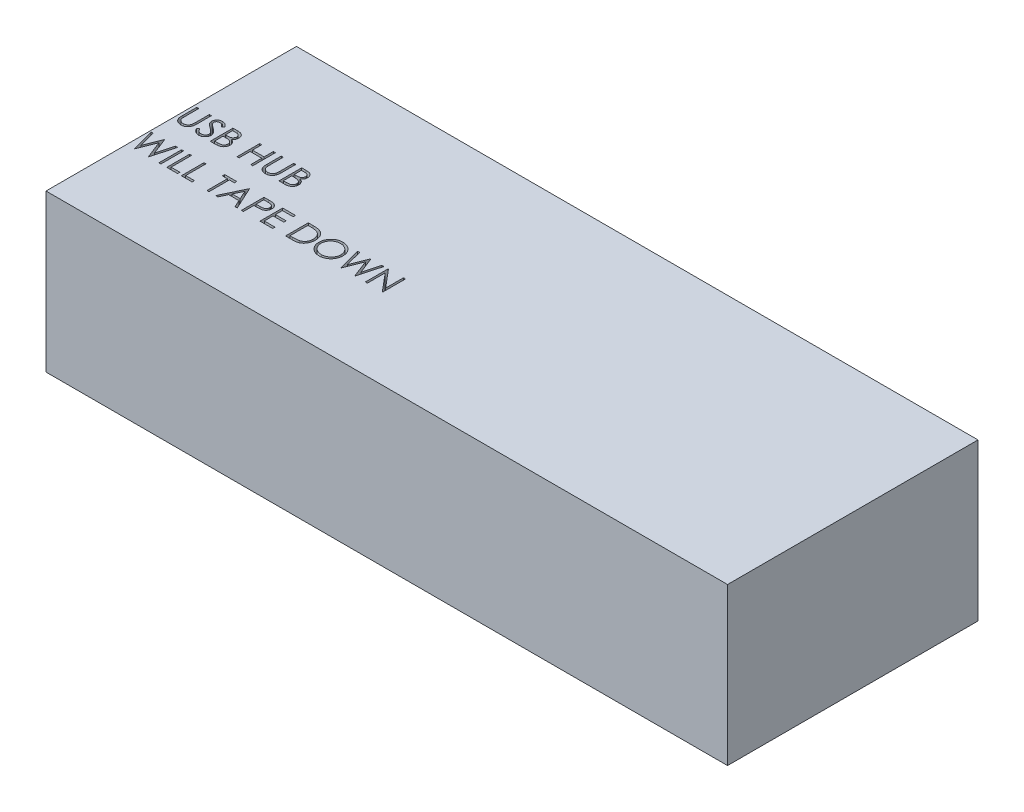
from build123d import *

# Parameters (mm, degrees)
SKETCH1_W           = 105.04
SKETCH1_H           = 38.6
BOSS_EXTRUDE1_DEPTH = 24.17
SKETCH2_W           = 0.314102564
SKETCH2_H           = 3.5
CUT_EXTRUDE1_DEPTH  = 25.17


with BuildPart() as part:
    # Sketch1 → Boss-Extrude1 (new body)
    with BuildSketch(Plane(origin=(0, 0, 0), x_dir=(1, 0, 0), z_dir=(0, 1, 0))):
        with Locations((52.52, 19.3)):
            Rectangle(SKETCH1_W, SKETCH1_H)
    extrude(amount=BOSS_EXTRUDE1_DEPTH)

    # Sketch2 → Cut-Extrude1 (cut, through all)
    with BuildSketch(Plane(origin=(0, 24.17, 0), x_dir=(1, 0, 0), z_dir=(0, 1, 0))):
        with BuildLine():
            Line((0.448717949, 22.8), (0.762820513, 22.8))
            Line((0.762820513, 22.8), (0.762820513, 20.702944712))
            add(Edge.make_bspline(
                [(0.762820513, 20.702944712), (0.762773769, 20.673263976), (0.762685064, 20.616939665), (0.763277578, 20.536771364), (0.764936946, 20.465498905), (0.765983106, 20.402847558), (0.768310439, 20.34910481), (0.770208486, 20.3039795), (0.772649043, 20.267685297), (0.775582161, 20.246504371), (0.776842949, 20.23739984)],
                knots=[0, 0, 0, 0, 8.9042e-05, 0.000168973, 0.000240502, 0.000302917, 0.000356945, 0.000401866, 0.000438432, 0.000465999, 0.000465999, 0.000465999, 0.000465999], degree=3))
            add(Edge.make_bspline(
                [(0.776842949, 20.23739984), (0.782020408, 20.204553076), (0.792083594, 20.140710347), (0.817729972, 20.049802065), (0.853547473, 19.967870607), (0.895990515, 19.892359316), (0.951923127, 19.825369956), (1.018926662, 19.763658303), (1.100104431, 19.709686499), (1.190365036, 19.660335687), (1.287650274, 19.620670604), (1.38706154, 19.59067724), (1.487104519, 19.57239834), (1.554080684, 19.570281801), (1.587339744, 19.569230769)],
                knots=[0, 0, 0, 0, 9.971e-05, 0.000193801, 0.000282365, 0.000367504, 0.000452699, 0.000543015, 0.000639862, 0.000744331, 0.000851226, 0.000954377, 0.001055468, 0.001155185, 0.001155185, 0.001155185, 0.001155185], degree=3))
            add(Edge.make_bspline(
                [(1.587339744, 19.569230769), (1.615893484, 19.57030462), (1.672836046, 19.572446118), (1.757442477, 19.585707549), (1.839842585, 19.609608115), (1.920443265, 19.640447873), (1.99599425, 19.681195464), (2.066537692, 19.728266303), (2.129501626, 19.78347718), (2.186959624, 19.844577524), (2.236994559, 19.913517324), (2.280365701, 19.988795462), (2.315891631, 20.071544809), (2.333435156, 20.129699231), (2.342447917, 20.159575321)],
                knots=[0, 0, 0, 0, 8.5678e-05, 0.00017086, 0.000256092, 0.000342674, 0.000429242, 0.000513055, 0.000596556, 0.000679898, 0.000764179, 0.00085149, 0.000940054, 0.001033621, 0.001033621, 0.001033621, 0.001033621], degree=3))
            add(Edge.make_bspline(
                [(2.342447917, 20.159575321), (2.345448042, 20.171923895), (2.35213353, 20.199441495), (2.358380575, 20.245962785), (2.364887101, 20.300852149), (2.369401671, 20.364503962), (2.373802891, 20.436704935), (2.376435964, 20.517831192), (2.377652997, 20.607588153), (2.378015677, 20.670225315), (2.378205128, 20.702944712)],
                knots=[0, 0, 0, 0, 3.81e-05, 8.4902e-05, 0.000140649, 0.000203941, 0.000276279, 0.000357657, 0.000447412, 0.000545571, 0.000545571, 0.000545571, 0.000545571], degree=3))
            Line((2.378205128, 20.702944712), (2.378205128, 22.8))
            Line((2.378205128, 22.8), (2.692307692, 22.8))
            Line((2.692307692, 22.8), (2.692307692, 20.686117788))
            add(Edge.make_bspline(
                [(2.692307692, 20.686117788), (2.692053572, 20.64801941), (2.691557641, 20.573668107), (2.687257064, 20.464716748), (2.680400064, 20.361363766), (2.670711976, 20.26359527), (2.657874973, 20.171761111), (2.643599753, 20.085056342), (2.625420219, 20.00410335), (2.604186818, 19.928270932), (2.57991327, 19.856085419), (2.548472122, 19.787576804), (2.513047622, 19.720662404), (2.471032969, 19.656354295), (2.423821586, 19.594367742), (2.370369906, 19.535078667), (2.312445745, 19.477539621), (2.249086185, 19.423226555), (2.18133566, 19.373417878), (2.109395702, 19.329620107), (2.033818933, 19.292596489), (1.954801806, 19.262120565), (1.872310604, 19.239205966), (1.786343244, 19.22213081), (1.69670405, 19.212428513), (1.635739394, 19.210986582), (1.604867788, 19.21025641)],
                knots=[0, 0, 0, 0, 0.000114291, 0.000223047, 0.000327049, 0.000424998, 0.000517708, 0.000605194, 0.000688542, 0.000766455, 0.0008414, 0.000916717, 0.000992315, 0.001068354, 0.001146882, 0.001225836, 0.001307639, 0.001391671, 0.001475952, 0.001559641, 0.001643989, 0.001728103, 0.001813335, 0.001900511, 0.00199079, 0.002083404, 0.002083404, 0.002083404, 0.002083404], degree=3))
            add(Edge.make_bspline(
                [(1.604867788, 19.21025641), (1.571198686, 19.211041176), (1.505140027, 19.212580882), (1.40780196, 19.221403632), (1.314487763, 19.238022027), (1.224211886, 19.25918197), (1.138203389, 19.288365708), (1.055309945, 19.322463832), (0.976951264, 19.364341093), (0.901856135, 19.410934486), (0.832031379, 19.463359124), (0.767933976, 19.520499298), (0.709458105, 19.581439675), (0.657589409, 19.646840041), (0.611468524, 19.716191748), (0.571738311, 19.789690988), (0.537625067, 19.867309304), (0.5200185, 19.921262504), (0.511117788, 19.94853766)],
                knots=[0, 0, 0, 0, 0.000101022, 0.000198206, 0.000292839, 0.000385177, 0.00047608, 0.000565014, 0.000653769, 0.000742283, 0.000829923, 0.000915339, 0.000999643, 0.001082971, 0.00116542, 0.001249186, 0.001333332, 0.001419362, 0.001419362, 0.001419362, 0.001419362], degree=3))
            add(Edge.make_bspline(
                [(0.511117788, 19.94853766), (0.50594063, 19.967170235), (0.494711259, 20.007584704), (0.482685961, 20.074471192), (0.47257688, 20.15148611), (0.463071321, 20.238634728), (0.457462363, 20.335984595), (0.452544925, 20.443493511), (0.448683306, 20.561291472), (0.448706078, 20.643345988), (0.448717949, 20.686117788)],
                knots=[0, 0, 0, 0, 5.799e-05, 0.000125782, 0.000203619, 0.000291034, 0.000388694, 0.000496078, 0.000613919, 0.000742226, 0.000742226, 0.000742226, 0.000742226], degree=3))
            Line((0.448717949, 20.686117788), (0.448717949, 22.8))
        make_face()
        with BuildLine():
            Line((3.230769231, 19.975180288), (3.526642628, 20.152564103))
            add(Edge.make_bspline(
                [(3.526642628, 20.152564103), (3.554160865, 20.106499718), (3.606884746, 20.018242134), (3.694836105, 19.898984093), (3.785969016, 19.797621937), (3.88095835, 19.714745329), (3.979224298, 19.649496442), (4.081408352, 19.603294211), (4.187166163, 19.574478235), (4.259139984, 19.570978149), (4.295072115, 19.569230769)],
                knots=[0, 0, 0, 0, 0.000160901, 0.00030828, 0.000443778, 0.00056903, 0.000685513, 0.000796284, 0.00090427, 0.001011928, 0.001011928, 0.001011928, 0.001011928], degree=3))
            add(Edge.make_bspline(
                [(4.295072115, 19.569230769), (4.325758976, 19.570085442), (4.386595749, 19.571779832), (4.476157992, 19.588060634), (4.563139794, 19.613072763), (4.645748432, 19.648893694), (4.722844046, 19.69223218), (4.790450742, 19.744578358), (4.848896855, 19.803184563), (4.89670597, 19.868567218), (4.933386005, 19.938884367), (4.961578073, 20.011060318), (4.977223147, 20.086228886), (4.9795799, 20.136839349), (4.980769231, 20.162379808)],
                knots=[0, 0, 0, 0, 9.1978e-05, 0.000182347, 0.000272202, 0.000362975, 0.000451852, 0.000536835, 0.000618639, 0.000699414, 0.000778765, 0.000855983, 0.0009312, 0.001007828, 0.001007828, 0.001007828, 0.001007828], degree=3))
            add(Edge.make_bspline(
                [(4.980769231, 20.162379808), (4.97929492, 20.191520657), (4.976297862, 20.250759747), (4.950966382, 20.3381594), (4.911117135, 20.42465197), (4.874354491, 20.478153235), (4.855268429, 20.505929487)],
                knots=[0, 0, 0, 0, 8.7281e-05, 0.000177429, 0.000270909, 0.000371844, 0.000371844, 0.000371844, 0.000371844], degree=3))
            add(Edge.make_bspline(
                [(4.855268429, 20.505929487), (4.839597815, 20.525976311), (4.806699321, 20.568062109), (4.750141808, 20.630707345), (4.683775694, 20.695325764), (4.609872139, 20.764384821), (4.52573905, 20.834672617), (4.434011536, 20.909540895), (4.332347677, 20.986142472), (4.26104818, 21.037515038), (4.224258814, 21.064022436)],
                knots=[0, 0, 0, 0, 7.6319e-05, 0.000160223, 0.000252933, 0.000354147, 0.000463581, 0.000581729, 0.000709336, 0.000845369, 0.000845369, 0.000845369, 0.000845369], degree=3))
            add(Edge.make_bspline(
                [(4.224258814, 21.064022436), (4.187434818, 21.090251024), (4.117030141, 21.140398086), (4.018571559, 21.21482237), (3.930527096, 21.282866239), (3.853288079, 21.345170251), (3.786888483, 21.401742856), (3.730805072, 21.452040795), (3.686466515, 21.497424356), (3.661810934, 21.526865698), (3.650741186, 21.540084135)],
                knots=[0, 0, 0, 0, 0.000135623, 0.000259301, 0.000370234, 0.000469439, 0.00055697, 0.000631911, 0.000695377, 0.00074709, 0.00074709, 0.00074709, 0.00074709], degree=3))
            add(Edge.make_bspline(
                [(3.650741186, 21.540084135), (3.635268641, 21.560685171), (3.604839804, 21.601199875), (3.564673798, 21.664524733), (3.530534636, 21.729347998), (3.503772304, 21.795843863), (3.481236085, 21.863078792), (3.466078154, 21.931930038), (3.456586757, 22.002088656), (3.455614771, 22.049302157), (3.455128205, 22.072936699)],
                knots=[0, 0, 0, 0, 7.727e-05, 0.000151962, 0.000224716, 0.000296717, 0.00036678, 0.0004372, 0.000507902, 0.000578771, 0.000578771, 0.000578771, 0.000578771], degree=3))
            add(Edge.make_bspline(
                [(3.455128205, 22.072936699), (3.456433414, 22.109966473), (3.459015934, 22.183234537), (3.480856451, 22.290265367), (3.515329345, 22.392451785), (3.563624233, 22.488782118), (3.625881586, 22.576748099), (3.69792756, 22.657361586), (3.783739046, 22.725130168), (3.87789167, 22.784342227), (3.980948042, 22.830688152), (4.088938945, 22.865649132), (4.202036017, 22.88545839), (4.278639152, 22.888301155), (4.317508013, 22.88974359)],
                knots=[0, 0, 0, 0, 0.000110999, 0.000219625, 0.000326272, 0.00043382, 0.000541574, 0.000648775, 0.000756959, 0.000868438, 0.000981703, 0.00109501, 0.001208203, 0.0013248, 0.0013248, 0.0013248, 0.0013248], degree=3))
            add(Edge.make_bspline(
                [(4.317508013, 22.88974359), (4.358752113, 22.888321038), (4.440773465, 22.885492037), (4.56142268, 22.860894506), (4.677583397, 22.820193834), (4.771026662, 22.774005176), (4.844159423, 22.72787376), (4.899932156, 22.685853936), (4.956449607, 22.637478827), (5.014167661, 22.582619581), (5.072108321, 22.52077283), (5.131131773, 22.452362141), (5.191376042, 22.377805585), (5.230131902, 22.324581085), (5.25, 22.297295673)],
                knots=[0, 0, 0, 0, 0.000123638, 0.000245877, 0.000367608, 0.000492088, 0.000557638, 0.000626769, 0.000701372, 0.00078072, 0.000865532, 0.000955497, 0.001051745, 0.001152989, 0.001152989, 0.001152989, 0.001152989], degree=3))
            Line((5.25, 22.297295673), (4.966045673, 22.082051282))
            add(Edge.make_bspline(
                [(4.966045673, 22.082051282), (4.948899741, 22.104139972), (4.915880684, 22.146677626), (4.865751197, 22.206248941), (4.818502549, 22.260665421), (4.771952149, 22.307930549), (4.728558518, 22.350632682), (4.686441475, 22.387192439), (4.646207124, 22.417968034), (4.595490213, 22.450811594), (4.531772495, 22.483368098), (4.451787959, 22.510917176), (4.368201684, 22.527472238), (4.311272052, 22.529661126), (4.282451923, 22.530769231)],
                knots=[0, 0, 0, 0, 8.3877e-05, 0.000161528, 0.000233552, 0.000299993, 0.000360485, 0.000416152, 0.000467195, 0.000512312, 0.000597287, 0.000681099, 0.000765389, 0.000851809, 0.000851809, 0.000851809, 0.000851809], degree=3))
            add(Edge.make_bspline(
                [(4.282451923, 22.530769231), (4.246295401, 22.529557531), (4.176570953, 22.527220882), (4.077580717, 22.501700896), (3.988486792, 22.461519036), (3.911934227, 22.405204058), (3.84819725, 22.338483065), (3.802091791, 22.26170421), (3.774341627, 22.176921808), (3.770955347, 22.117780151), (3.769230769, 22.087660256)],
                knots=[0, 0, 0, 0, 0.000108248, 0.000208746, 0.00030443, 0.000399793, 0.000492054, 0.00057947, 0.000666386, 0.000756591, 0.000756591, 0.000756591, 0.000756591], degree=3))
            add(Edge.make_bspline(
                [(3.769230769, 22.087660256), (3.769623896, 22.068908778), (3.770410792, 22.031375158), (3.78138559, 21.975923736), (3.795484919, 21.920612397), (3.81782755, 21.865689814), (3.848672854, 21.810195455), (3.88917803, 21.753173718), (3.940191342, 21.694122009), (3.979268354, 21.655714635), (3.99989984, 21.635436699)],
                knots=[0, 0, 0, 0, 5.616e-05, 0.000112411, 0.000169046, 0.000227244, 0.000289691, 0.000359134, 0.000436702, 0.000523463, 0.000523463, 0.000523463, 0.000523463], degree=3))
            add(Edge.make_bspline(
                [(3.99989984, 21.635436699), (4.007561212, 21.628599673), (4.025762879, 21.612356465), (4.059038805, 21.585764184), (4.102981603, 21.552961412), (4.156443804, 21.512374095), (4.220411166, 21.465292633), (4.294890722, 21.412319021), (4.379052255, 21.351733562), (4.438774171, 21.309376021), (4.470352564, 21.286979167)],
                knots=[0, 0, 0, 0, 3.0802e-05, 7.3177e-05, 0.000127725, 0.000195314, 0.000274544, 0.000365991, 0.000469501, 0.000585644, 0.000585644, 0.000585644, 0.000585644], degree=3))
            add(Edge.make_bspline(
                [(4.470352564, 21.286979167), (4.508338477, 21.259337807), (4.581892934, 21.205814145), (4.686550514, 21.125398465), (4.781444322, 21.046750697), (4.866907525, 20.97037309), (4.943784434, 20.896844997), (5.011222154, 20.825281816), (5.069907835, 20.756196244), (5.133087053, 20.667623668), (5.197644873, 20.558842584), (5.25308638, 20.425564345), (5.288044728, 20.291768025), (5.292616243, 20.201841188), (5.294871795, 20.157471955)],
                knots=[0, 0, 0, 0, 0.000140932, 0.000272896, 0.000395881, 0.000510584, 0.000616697, 0.000714904, 0.000805482, 0.000888372, 0.001041088, 0.001183793, 0.001320341, 0.001453327, 0.001453327, 0.001453327, 0.001453327], degree=3))
            add(Edge.make_bspline(
                [(5.294871795, 20.157471955), (5.294214657, 20.12609359), (5.292913142, 20.063946206), (5.277952228, 19.97269113), (5.256032563, 19.88406026), (5.222995329, 19.799149147), (5.182672171, 19.716404385), (5.131505923, 19.637996484), (5.072198238, 19.562190086), (5.004164473, 19.491006594), (4.929718571, 19.425660398), (4.851034876, 19.367531337), (4.767984603, 19.319063014), (4.681018286, 19.279512172), (4.59011595, 19.248578654), (4.495308166, 19.226165785), (4.396438655, 19.212410074), (4.329238173, 19.210982313), (4.295072115, 19.21025641)],
                knots=[0, 0, 0, 0, 9.4044e-05, 0.000186263, 0.000276729, 0.000367488, 0.000459046, 0.000552398, 0.000647774, 0.000747454, 0.000847311, 0.000944634, 0.001040472, 0.001135227, 0.001230788, 0.001328063, 0.00142712, 0.00152957, 0.00152957, 0.00152957, 0.00152957], degree=3))
            add(Edge.make_bspline(
                [(4.295072115, 19.21025641), (4.268636772, 19.210767592), (4.216099012, 19.211783517), (4.13838953, 19.220764798), (4.062249941, 19.233471901), (3.988635659, 19.253645971), (3.916598248, 19.278122948), (3.846451013, 19.308261281), (3.778159959, 19.344378482), (3.711342376, 19.385673507), (3.646168202, 19.433731252), (3.583248734, 19.489704748), (3.520519548, 19.552050253), (3.459832152, 19.622460816), (3.399959008, 19.699798899), (3.342080598, 19.784788083), (3.28499888, 19.876965436), (3.249183413, 19.941830522), (3.230769231, 19.975180288)],
                knots=[0, 0, 0, 0, 7.9276e-05, 0.000157554, 0.000234438, 0.000310629, 0.000386236, 0.000462555, 0.000539392, 0.000617798, 0.000698008, 0.000781971, 0.000870217, 0.00096315, 0.001060616, 0.001163492, 0.001271478, 0.00138575, 0.00138575, 0.00138575, 0.00138575], degree=3))
        make_face()
        with BuildLine():
            Line((6.012820513, 22.8), (6.695713141, 22.8))
            add(Edge.make_bspline(
                [(6.695713141, 22.8), (6.729141619, 22.79982425), (6.79393433, 22.799483602), (6.888153771, 22.79420047), (6.976402582, 22.786996801), (7.058706354, 22.775566708), (7.135027057, 22.761774931), (7.205594694, 22.745073115), (7.270184866, 22.725046501), (7.347297603, 22.69320022), (7.435218264, 22.645877051), (7.530416656, 22.575948486), (7.611820896, 22.490416023), (7.682007213, 22.393933368), (7.737808332, 22.287797596), (7.77817763, 22.174538407), (7.803735505, 22.055616665), (7.806363939, 21.973973487), (7.807692308, 21.93271234)],
                knots=[0, 0, 0, 0, 0.00010027, 0.000194349, 0.000283026, 0.000365821, 0.000443519, 0.000515622, 0.000583254, 0.00064614, 0.000765662, 0.000881909, 0.000998927, 0.001118415, 0.001238844, 0.00135727, 0.001478274, 0.001601912, 0.001601912, 0.001601912, 0.001601912], degree=3))
            add(Edge.make_bspline(
                [(7.807692308, 21.93271234), (7.806599089, 21.894059784), (7.804450812, 21.818103867), (7.783908053, 21.707009758), (7.751747384, 21.601258539), (7.707042135, 21.501236154), (7.648940139, 21.40920254), (7.58008182, 21.324415274), (7.497005018, 21.250464217), (7.434761778, 21.209121315), (7.403145032, 21.188120994)],
                knots=[0, 0, 0, 0, 0.000115857, 0.00022767, 0.000337672, 0.000446877, 0.000555233, 0.000663318, 0.000773539, 0.000887324, 0.000887324, 0.000887324, 0.000887324], degree=3))
            add(Edge.make_bspline(
                [(7.403145032, 21.188120994), (7.44290546, 21.172855995), (7.518977007, 21.14365027), (7.623663019, 21.092014806), (7.713857864, 21.035852696), (7.79025501, 20.974520846), (7.855592665, 20.908412035), (7.912645607, 20.836556921), (7.961326981, 20.758018163), (8.003039905, 20.673614627), (8.035588661, 20.584208159), (8.059964565, 20.490637383), (8.073932014, 20.393237828), (8.075919655, 20.326952448), (8.076923077, 20.293489583)],
                knots=[0, 0, 0, 0, 0.000127722, 0.000244363, 0.000349599, 0.000445847, 0.000537565, 0.000627901, 0.000720503, 0.000814257, 0.000909859, 0.001005428, 0.001103887, 0.001204268, 0.001204268, 0.001204268, 0.001204268], degree=3))
            add(Edge.make_bspline(
                [(8.076923077, 20.293489583), (8.075946231, 20.259322711), (8.074024259, 20.192098433), (8.059844287, 20.093343299), (8.03583518, 19.998968352), (8.002764034, 19.908363169), (7.959601719, 19.821703035), (7.907073755, 19.738889771), (7.844442191, 19.66075544), (7.774379322, 19.586431817), (7.695117177, 19.51960403), (7.609601422, 19.460088323), (7.516755102, 19.411142261), (7.418103108, 19.370026239), (7.312538792, 19.338619041), (7.200536185, 19.316646467), (7.082191883, 19.30184143), (7.000982132, 19.300624225), (6.959334936, 19.3)],
                knots=[0, 0, 0, 0, 0.000102481, 0.000201635, 0.000298562, 0.000394165, 0.000490425, 0.000588455, 0.000687769, 0.000790423, 0.000894381, 0.000998232, 0.001102369, 0.001208616, 0.001318415, 0.001432129, 0.001550749, 0.00167562, 0.00167562, 0.00167562, 0.00167562], degree=3))
            Line((6.959334936, 19.3), (6.012820513, 19.3))
            Line((6.012820513, 19.3), (6.012820513, 22.8))
        make_face()
        with BuildLine():
            Line((6.326923077, 22.441025641), (6.326923077, 21.319230769))
            Line((6.326923077, 21.319230769), (6.537960737, 21.319230769))
            add(Edge.make_bspline(
                [(6.537960737, 21.319230769), (6.568809533, 21.319630692), (6.628415692, 21.320403425), (6.714735588, 21.322616942), (6.794860607, 21.328814985), (6.86865244, 21.335011248), (6.935994884, 21.345085835), (6.996738745, 21.357077958), (7.051837342, 21.369760863), (7.115376888, 21.39133035), (7.187449836, 21.423208025), (7.26428294, 21.472679861), (7.33201741, 21.531604215), (7.389214597, 21.599595176), (7.436026068, 21.674461362), (7.468539783, 21.755008243), (7.490587067, 21.839228375), (7.492578599, 21.897046627), (7.493589744, 21.926402244)],
                knots=[0, 0, 0, 0, 9.2559e-05, 0.000178842, 0.000258967, 0.000333616, 0.000400942, 0.000463093, 0.000519379, 0.000570374, 0.000664201, 0.000755025, 0.000843472, 0.000932526, 0.001020669, 0.001107124, 0.001192318, 0.001280185, 0.001280185, 0.001280185, 0.001280185], degree=3))
            add(Edge.make_bspline(
                [(7.493589744, 21.926402244), (7.493063563, 21.945828015), (7.492031404, 21.983933787), (7.483578101, 22.039483141), (7.469210526, 22.091726894), (7.450756233, 22.141381004), (7.424967545, 22.186892854), (7.394604081, 22.22983605), (7.357918391, 22.268748169), (7.316161078, 22.305117667), (7.268152455, 22.337362195), (7.213921164, 22.365602958), (7.152733487, 22.388343735), (7.085620632, 22.408259887), (7.011549544, 22.422248181), (6.931374991, 22.433901569), (6.844440272, 22.439834311), (6.784295169, 22.440619673), (6.753205128, 22.441025641)],
                knots=[0, 0, 0, 0, 5.8261e-05, 0.000114285, 0.000168029, 0.000220632, 0.000272728, 0.000324483, 0.000378062, 0.000432741, 0.000490301, 0.000551137, 0.000615721, 0.000685833, 0.000760908, 0.00084162, 0.000928788, 0.00102206, 0.00102206, 0.00102206, 0.00102206], degree=3))
            Line((6.753205128, 22.441025641), (6.326923077, 22.441025641))
        make_face(mode=Mode.SUBTRACT)
        with BuildLine():
            Line((6.326923077, 20.96025641), (6.326923077, 19.658974359))
            Line((6.326923077, 19.658974359), (6.774238782, 19.658974359))
            add(Edge.make_bspline(
                [(6.774238782, 19.658974359), (6.806257708, 19.659358106), (6.867969967, 19.660097729), (6.957071197, 19.662512283), (7.0396543, 19.668004559), (7.115342436, 19.676650409), (7.184952889, 19.686028858), (7.247650592, 19.698640139), (7.303943785, 19.713089099), (7.369218093, 19.735423272), (7.442721601, 19.770119743), (7.521932458, 19.822433969), (7.592358676, 19.884757277), (7.652163935, 19.956888191), (7.701176924, 20.035319518), (7.736832379, 20.118464868), (7.758823235, 20.204950395), (7.761485405, 20.263917108), (7.762820513, 20.293489583)],
                knots=[0, 0, 0, 0, 9.6064e-05, 0.000185151, 0.000267373, 0.000344257, 0.000413665, 0.000478015, 0.000536005, 0.000587888, 0.000684801, 0.000778918, 0.000871787, 0.000965866, 0.001059062, 0.00114827, 0.001236355, 0.001324974, 0.001324974, 0.001324974, 0.001324974], degree=3))
            add(Edge.make_bspline(
                [(7.762820513, 20.293489583), (7.762544408, 20.311982924), (7.761996653, 20.348671306), (7.753736038, 20.402587125), (7.741722169, 20.454812998), (7.726190735, 20.505490739), (7.703571268, 20.553704115), (7.677164723, 20.600406675), (7.646203321, 20.645660154), (7.597959155, 20.702872407), (7.527787171, 20.76878942), (7.428080395, 20.833326923), (7.314708097, 20.88537473), (7.232480604, 20.907474206), (7.190004006, 20.918890224)],
                knots=[0, 0, 0, 0, 5.5429e-05, 0.000109963, 0.000163198, 0.000216191, 0.000268588, 0.000322593, 0.000377046, 0.000432793, 0.000546889, 0.000664343, 0.000787646, 0.000919405, 0.000919405, 0.000919405, 0.000919405], degree=3))
            add(Edge.make_bspline(
                [(7.190004006, 20.918890224), (7.172974911, 20.922345308), (7.136052318, 20.929836643), (7.075844738, 20.937744346), (7.007108869, 20.944789406), (6.929685992, 20.950000564), (6.843478151, 20.955387107), (6.748301232, 20.957481929), (6.644543917, 20.959981189), (6.572551545, 20.960162323), (6.53515625, 20.96025641)],
                knots=[0, 0, 0, 0, 5.2115e-05, 0.000112995, 0.000182062, 0.000259389, 0.000345767, 0.00044116, 0.000544948, 0.000657129, 0.000657129, 0.000657129, 0.000657129], degree=3))
            Line((6.53515625, 20.96025641), (6.326923077, 20.96025641))
        make_face(mode=Mode.SUBTRACT)
        Polygon((10.141025641, 22.8), (10.455128205, 22.8), (10.455128205, 21.364102564), (12.25, 21.364102564), (12.25, 22.8), (12.564102564, 22.8), (12.564102564, 19.3), (12.25, 19.3), (12.25, 21.005128205), (10.455128205, 21.005128205), (10.455128205, 19.3), (10.141025641, 19.3), align=None)
        with BuildLine():
            Line((13.461538462, 22.8), (13.775641026, 22.8))
            Line((13.775641026, 22.8), (13.775641026, 20.702944712))
            add(Edge.make_bspline(
                [(13.775641026, 20.702944712), (13.775594282, 20.673263976), (13.775505577, 20.616939665), (13.776098091, 20.536771364), (13.777757459, 20.465498905), (13.778803619, 20.402847558), (13.781130952, 20.34910481), (13.783028999, 20.3039795), (13.785469556, 20.267685297), (13.788402673, 20.246504371), (13.789663462, 20.23739984)],
                knots=[0, 0, 0, 0, 8.9042e-05, 0.000168973, 0.000240502, 0.000302917, 0.000356945, 0.000401866, 0.000438432, 0.000465999, 0.000465999, 0.000465999, 0.000465999], degree=3))
            add(Edge.make_bspline(
                [(13.789663462, 20.23739984), (13.79484092, 20.204553076), (13.804904107, 20.140710347), (13.830550484, 20.049802065), (13.866367985, 19.967870607), (13.908811028, 19.892359316), (13.96474364, 19.825369956), (14.031747175, 19.763658303), (14.112924943, 19.709686499), (14.203185549, 19.660335687), (14.300470787, 19.620670604), (14.399882053, 19.59067724), (14.499925032, 19.57239834), (14.566901197, 19.570281801), (14.600160256, 19.569230769)],
                knots=[0, 0, 0, 0, 9.971e-05, 0.000193801, 0.000282365, 0.000367504, 0.000452699, 0.000543015, 0.000639862, 0.000744331, 0.000851226, 0.000954377, 0.001055468, 0.001155185, 0.001155185, 0.001155185, 0.001155185], degree=3))
            add(Edge.make_bspline(
                [(14.600160256, 19.569230769), (14.628713997, 19.57030462), (14.685656559, 19.572446118), (14.770262989, 19.585707549), (14.852663098, 19.609608115), (14.933263778, 19.640447873), (15.008814762, 19.681195464), (15.079358204, 19.728266303), (15.142322139, 19.78347718), (15.199780136, 19.844577524), (15.249815072, 19.913517324), (15.293186214, 19.988795462), (15.328712144, 20.071544809), (15.346255668, 20.129699231), (15.355268429, 20.159575321)],
                knots=[0, 0, 0, 0, 8.5678e-05, 0.00017086, 0.000256092, 0.000342674, 0.000429242, 0.000513055, 0.000596556, 0.000679898, 0.000764179, 0.00085149, 0.000940054, 0.001033621, 0.001033621, 0.001033621, 0.001033621], degree=3))
            add(Edge.make_bspline(
                [(15.355268429, 20.159575321), (15.358268555, 20.171923895), (15.364954043, 20.199441495), (15.371201088, 20.245962785), (15.377707613, 20.300852149), (15.382222183, 20.364503962), (15.386623404, 20.436704935), (15.389256477, 20.517831192), (15.39047351, 20.607588153), (15.39083619, 20.670225315), (15.391025641, 20.702944712)],
                knots=[0, 0, 0, 0, 3.81e-05, 8.4902e-05, 0.000140649, 0.000203941, 0.000276279, 0.000357657, 0.000447412, 0.000545571, 0.000545571, 0.000545571, 0.000545571], degree=3))
            Line((15.391025641, 20.702944712), (15.391025641, 22.8))
            Line((15.391025641, 22.8), (15.705128205, 22.8))
            Line((15.705128205, 22.8), (15.705128205, 20.686117788))
            add(Edge.make_bspline(
                [(15.705128205, 20.686117788), (15.704874085, 20.64801941), (15.704378153, 20.573668107), (15.700077577, 20.464716748), (15.693220577, 20.361363766), (15.683532489, 20.26359527), (15.670695486, 20.171761111), (15.656420265, 20.085056342), (15.638240732, 20.00410335), (15.617007331, 19.928270932), (15.592733783, 19.856085419), (15.561292635, 19.787576804), (15.525868135, 19.720662404), (15.483853482, 19.656354295), (15.436642099, 19.594367742), (15.383190419, 19.535078667), (15.325266258, 19.477539621), (15.261906698, 19.423226555), (15.194156173, 19.373417878), (15.122216215, 19.329620107), (15.046639445, 19.292596489), (14.967622319, 19.262120565), (14.885131116, 19.239205966), (14.799163757, 19.22213081), (14.709524563, 19.212428513), (14.648559907, 19.210986582), (14.617688301, 19.21025641)],
                knots=[0, 0, 0, 0, 0.000114291, 0.000223047, 0.000327049, 0.000424998, 0.000517708, 0.000605194, 0.000688542, 0.000766455, 0.0008414, 0.000916717, 0.000992315, 0.001068354, 0.001146882, 0.001225836, 0.001307639, 0.001391671, 0.001475952, 0.001559641, 0.001643989, 0.001728103, 0.001813335, 0.001900511, 0.00199079, 0.002083404, 0.002083404, 0.002083404, 0.002083404], degree=3))
            add(Edge.make_bspline(
                [(14.617688301, 19.21025641), (14.584019199, 19.211041176), (14.51796054, 19.212580882), (14.420622473, 19.221403632), (14.327308276, 19.238022027), (14.237032399, 19.25918197), (14.151023902, 19.288365708), (14.068130458, 19.322463832), (13.989771777, 19.364341093), (13.914676648, 19.410934486), (13.844851892, 19.463359124), (13.780754489, 19.520499298), (13.722278618, 19.581439675), (13.670409922, 19.646840041), (13.624289037, 19.716191748), (13.584558824, 19.789690988), (13.55044558, 19.867309304), (13.532839013, 19.921262504), (13.523938301, 19.94853766)],
                knots=[0, 0, 0, 0, 0.000101022, 0.000198206, 0.000292839, 0.000385177, 0.00047608, 0.000565014, 0.000653769, 0.000742283, 0.000829923, 0.000915339, 0.000999643, 0.001082971, 0.00116542, 0.001249186, 0.001333332, 0.001419362, 0.001419362, 0.001419362, 0.001419362], degree=3))
            add(Edge.make_bspline(
                [(13.523938301, 19.94853766), (13.518761143, 19.967170235), (13.507531772, 20.007584704), (13.495506474, 20.074471192), (13.485397392, 20.15148611), (13.475891834, 20.238634728), (13.470282876, 20.335984595), (13.465365438, 20.443493511), (13.461503819, 20.561291472), (13.461526591, 20.643345988), (13.461538462, 20.686117788)],
                knots=[0, 0, 0, 0, 5.799e-05, 0.000125782, 0.000203619, 0.000291034, 0.000388694, 0.000496078, 0.000613919, 0.000742226, 0.000742226, 0.000742226, 0.000742226], degree=3))
            Line((13.461538462, 20.686117788), (13.461538462, 22.8))
        make_face()
        with BuildLine():
            Line((16.602564103, 22.8), (17.285456731, 22.8))
            add(Edge.make_bspline(
                [(17.285456731, 22.8), (17.318885209, 22.79982425), (17.383677919, 22.799483602), (17.477897361, 22.79420047), (17.566146172, 22.786996801), (17.648449944, 22.775566708), (17.724770647, 22.761774931), (17.795338284, 22.745073115), (17.859928456, 22.725046501), (17.937041192, 22.69320022), (18.024961853, 22.645877051), (18.120160246, 22.575948486), (18.201564485, 22.490416023), (18.271750803, 22.393933368), (18.327551922, 22.287797596), (18.36792122, 22.174538407), (18.393479095, 22.055616665), (18.396107529, 21.973973487), (18.397435897, 21.93271234)],
                knots=[0, 0, 0, 0, 0.00010027, 0.000194349, 0.000283026, 0.000365821, 0.000443519, 0.000515622, 0.000583254, 0.00064614, 0.000765662, 0.000881909, 0.000998927, 0.001118415, 0.001238844, 0.00135727, 0.001478274, 0.001601912, 0.001601912, 0.001601912, 0.001601912], degree=3))
            add(Edge.make_bspline(
                [(18.397435897, 21.93271234), (18.396342679, 21.894059784), (18.394194402, 21.818103867), (18.373651642, 21.707009758), (18.341490974, 21.601258539), (18.296785725, 21.501236154), (18.238683729, 21.40920254), (18.16982541, 21.324415274), (18.086748607, 21.250464217), (18.024505367, 21.209121315), (17.992888622, 21.188120994)],
                knots=[0, 0, 0, 0, 0.000115857, 0.00022767, 0.000337672, 0.000446877, 0.000555233, 0.000663318, 0.000773539, 0.000887324, 0.000887324, 0.000887324, 0.000887324], degree=3))
            add(Edge.make_bspline(
                [(17.992888622, 21.188120994), (18.032649049, 21.172855995), (18.108720597, 21.14365027), (18.213406609, 21.092014806), (18.303601454, 21.035852696), (18.3799986, 20.974520846), (18.445336255, 20.908412035), (18.502389197, 20.836556921), (18.551070571, 20.758018163), (18.592783494, 20.673614627), (18.62533225, 20.584208159), (18.649708155, 20.490637383), (18.663675604, 20.393237828), (18.665663245, 20.326952448), (18.666666667, 20.293489583)],
                knots=[0, 0, 0, 0, 0.000127722, 0.000244363, 0.000349599, 0.000445847, 0.000537565, 0.000627901, 0.000720503, 0.000814257, 0.000909859, 0.001005428, 0.001103887, 0.001204268, 0.001204268, 0.001204268, 0.001204268], degree=3))
            add(Edge.make_bspline(
                [(18.666666667, 20.293489583), (18.665689821, 20.259322711), (18.663767849, 20.192098433), (18.649587877, 20.093343299), (18.62557877, 19.998968352), (18.592507624, 19.908363169), (18.549345309, 19.821703035), (18.496817345, 19.738889771), (18.434185781, 19.66075544), (18.364122912, 19.586431817), (18.284860767, 19.51960403), (18.199345012, 19.460088323), (18.106498692, 19.411142261), (18.007846698, 19.370026239), (17.902282382, 19.338619041), (17.790279774, 19.316646467), (17.671935472, 19.30184143), (17.590725721, 19.300624225), (17.549078526, 19.3)],
                knots=[0, 0, 0, 0, 0.000102481, 0.000201635, 0.000298562, 0.000394165, 0.000490425, 0.000588455, 0.000687769, 0.000790423, 0.000894381, 0.000998232, 0.001102369, 0.001208616, 0.001318415, 0.001432129, 0.001550749, 0.00167562, 0.00167562, 0.00167562, 0.00167562], degree=3))
            Line((17.549078526, 19.3), (16.602564103, 19.3))
            Line((16.602564103, 19.3), (16.602564103, 22.8))
        make_face()
        with BuildLine():
            Line((16.916666667, 22.441025641), (16.916666667, 21.319230769))
            Line((16.916666667, 21.319230769), (17.127704327, 21.319230769))
            add(Edge.make_bspline(
                [(17.127704327, 21.319230769), (17.158553122, 21.319630692), (17.218159282, 21.320403425), (17.304479178, 21.322616942), (17.384604196, 21.328814985), (17.458396029, 21.335011248), (17.525738473, 21.345085835), (17.586482335, 21.357077958), (17.641580932, 21.369760863), (17.705120477, 21.39133035), (17.777193426, 21.423208025), (17.85402653, 21.472679861), (17.921761, 21.531604215), (17.978958187, 21.599595176), (18.025769658, 21.674461362), (18.058283373, 21.755008243), (18.080330657, 21.839228375), (18.082322188, 21.897046627), (18.083333333, 21.926402244)],
                knots=[0, 0, 0, 0, 9.2559e-05, 0.000178842, 0.000258967, 0.000333616, 0.000400942, 0.000463093, 0.000519379, 0.000570374, 0.000664201, 0.000755025, 0.000843472, 0.000932526, 0.001020669, 0.001107124, 0.001192318, 0.001280185, 0.001280185, 0.001280185, 0.001280185], degree=3))
            add(Edge.make_bspline(
                [(18.083333333, 21.926402244), (18.082807153, 21.945828015), (18.081774993, 21.983933787), (18.073321691, 22.039483141), (18.058954116, 22.091726894), (18.040499823, 22.141381004), (18.014711134, 22.186892854), (17.984347671, 22.22983605), (17.947661981, 22.268748169), (17.905904668, 22.305117667), (17.857896045, 22.337362195), (17.803664753, 22.365602958), (17.742477076, 22.388343735), (17.675364221, 22.408259887), (17.601293134, 22.422248181), (17.52111858, 22.433901569), (17.434183861, 22.439834311), (17.374038759, 22.440619673), (17.342948718, 22.441025641)],
                knots=[0, 0, 0, 0, 5.8261e-05, 0.000114285, 0.000168029, 0.000220632, 0.000272728, 0.000324483, 0.000378062, 0.000432741, 0.000490301, 0.000551137, 0.000615721, 0.000685833, 0.000760908, 0.00084162, 0.000928788, 0.00102206, 0.00102206, 0.00102206, 0.00102206], degree=3))
            Line((17.342948718, 22.441025641), (16.916666667, 22.441025641))
        make_face(mode=Mode.SUBTRACT)
        with BuildLine():
            Line((16.916666667, 20.96025641), (16.916666667, 19.658974359))
            Line((16.916666667, 19.658974359), (17.363982372, 19.658974359))
            add(Edge.make_bspline(
                [(17.363982372, 19.658974359), (17.396001298, 19.659358106), (17.457713556, 19.660097729), (17.546814786, 19.662512283), (17.62939789, 19.668004559), (17.705086026, 19.676650409), (17.774696479, 19.686028858), (17.837394182, 19.698640139), (17.893687375, 19.713089099), (17.958961683, 19.735423272), (18.032465191, 19.770119743), (18.111676047, 19.822433969), (18.182102266, 19.884757277), (18.241907525, 19.956888191), (18.290920513, 20.035319518), (18.326575968, 20.118464868), (18.348566825, 20.204950395), (18.351228994, 20.263917108), (18.352564103, 20.293489583)],
                knots=[0, 0, 0, 0, 9.6064e-05, 0.000185151, 0.000267373, 0.000344257, 0.000413665, 0.000478015, 0.000536005, 0.000587888, 0.000684801, 0.000778918, 0.000871787, 0.000965866, 0.001059062, 0.00114827, 0.001236355, 0.001324974, 0.001324974, 0.001324974, 0.001324974], degree=3))
            add(Edge.make_bspline(
                [(18.352564103, 20.293489583), (18.352287998, 20.311982924), (18.351740243, 20.348671306), (18.343479628, 20.402587125), (18.331465758, 20.454812998), (18.315934325, 20.505490739), (18.293314857, 20.553704115), (18.266908312, 20.600406675), (18.235946911, 20.645660154), (18.187702745, 20.702872407), (18.11753076, 20.76878942), (18.017823985, 20.833326923), (17.904451687, 20.88537473), (17.822224194, 20.907474206), (17.779747596, 20.918890224)],
                knots=[0, 0, 0, 0, 5.5429e-05, 0.000109963, 0.000163198, 0.000216191, 0.000268588, 0.000322593, 0.000377046, 0.000432793, 0.000546889, 0.000664343, 0.000787646, 0.000919405, 0.000919405, 0.000919405, 0.000919405], degree=3))
            add(Edge.make_bspline(
                [(17.779747596, 20.918890224), (17.7627185, 20.922345308), (17.725795908, 20.929836643), (17.665588328, 20.937744346), (17.596852459, 20.944789406), (17.519429581, 20.950000564), (17.43322174, 20.955387107), (17.338044822, 20.957481929), (17.234287507, 20.959981189), (17.162295135, 20.960162323), (17.12489984, 20.96025641)],
                knots=[0, 0, 0, 0, 5.2115e-05, 0.000112995, 0.000182062, 0.000259389, 0.000345767, 0.00044116, 0.000544948, 0.000657129, 0.000657129, 0.000657129, 0.000657129], degree=3))
            Line((17.12489984, 20.96025641), (16.916666667, 20.96025641))
        make_face(mode=Mode.SUBTRACT)
        Polygon((0.224358974, 15.966666667), (0.548277244, 15.966666667), (1.233974359, 13.39775641), (2.252003205, 15.966666667), (2.297576122, 15.966666667), (3.298076923, 13.417387821), (3.986578526, 15.966666667), (4.307692308, 15.966666667), (3.363982372, 12.466666667), (3.319110577, 12.466666667), (2.266025641, 15.142147436), (1.201722756, 12.466666667), (1.15614984, 12.466666667), align=None)
        with Locations((5.092948718, 14.216666667)):
            Rectangle(SKETCH2_W, SKETCH2_H)
        Polygon((6.147435897, 15.966666667), (6.461538462, 15.966666667), (6.461538462, 12.825641026), (7.807692308, 12.825641026), (7.807692308, 12.466666667), (6.147435897, 12.466666667), align=None)
        Polygon((8.391025641, 15.966666667), (8.705128205, 15.966666667), (8.705128205, 12.825641026), (10.051282051, 12.825641026), (10.051282051, 12.466666667), (8.391025641, 12.466666667), align=None)
        Polygon((11.576923077, 15.607692308), (11.576923077, 15.966666667), (13.416666667, 15.966666667), (13.416666667, 15.607692308), (12.653846154, 15.607692308), (12.653846154, 12.466666667), (12.33974359, 12.466666667), (12.33974359, 15.607692308), align=None)
        Polygon((15.391025641, 15.966666667), (17.006410256, 12.466666667), (16.664963942, 12.466666667), (16.147536058, 13.588461538), (14.560897436, 13.588461538), (14.029447115, 12.466666667), (13.685897436, 12.466666667), (15.346153846, 15.966666667), align=None)
        Polygon((15.365084135, 15.283774038), (14.731971154, 13.947435897), (15.982071314, 13.947435897), align=None, mode=Mode.SUBTRACT)
        with BuildLine():
            Line((17.634615385, 15.966666667), (18.321013622, 15.966666667))
            add(Edge.make_bspline(
                [(18.321013622, 15.966666667), (18.368224528, 15.96661477), (18.458682721, 15.966515335), (18.588397776, 15.963500589), (18.706207508, 15.959473897), (18.811857889, 15.953892004), (18.905673987, 15.947295414), (18.987231287, 15.938043374), (19.057170843, 15.928383079), (19.099077292, 15.918561672), (19.118189103, 15.914082532)],
                knots=[0, 0, 0, 0, 0.000141628, 0.000271366, 0.00038923, 0.000495248, 0.00058876, 0.000671296, 0.000741499, 0.00080036, 0.00080036, 0.00080036, 0.00080036], degree=3))
            add(Edge.make_bspline(
                [(19.118189103, 15.914082532), (19.142382636, 15.907460582), (19.190199614, 15.894372721), (19.259100657, 15.868158997), (19.324654502, 15.837076832), (19.387086061, 15.801652892), (19.445628144, 15.760367328), (19.501154185, 15.71489371), (19.553174165, 15.664182142), (19.601395557, 15.608801402), (19.645680354, 15.549681192), (19.683810037, 15.485938962), (19.715737264, 15.418647658), (19.743120536, 15.347854087), (19.76282899, 15.272963764), (19.77767589, 15.194497051), (19.787099517, 15.112462361), (19.788002079, 15.056402494), (19.788461538, 15.027864583)],
                knots=[0, 0, 0, 0, 7.5216e-05, 0.00014866, 0.000220794, 0.000292713, 0.000363707, 0.000435434, 0.000507823, 0.000581364, 0.000655543, 0.000729131, 0.000803767, 0.000878771, 0.000956497, 0.001035702, 0.001118238, 0.001203821, 0.001203821, 0.001203821, 0.001203821], degree=3))
            add(Edge.make_bspline(
                [(19.788461538, 15.027864583), (19.788040114, 14.999086807), (19.787215568, 14.942781143), (19.777319282, 14.860408354), (19.763989091, 14.781689964), (19.743492039, 14.706800514), (19.716646365, 14.636184743), (19.685154313, 14.568763511), (19.647170782, 14.505683839), (19.603525952, 14.446716722), (19.554974358, 14.39180681), (19.50172142, 14.341352015), (19.443982127, 14.295647677), (19.381939979, 14.254591333), (19.314990131, 14.219135053), (19.244147977, 14.187377749), (19.168797761, 14.160706688), (19.116655247, 14.146676626), (19.090144231, 14.139543269)],
                knots=[0, 0, 0, 0, 8.6284e-05, 0.00016882, 0.000248587, 0.000325638, 0.000401297, 0.000474998, 0.000548586, 0.000621785, 0.0006948, 0.0007682, 0.000841564, 0.000915458, 0.000991056, 0.00106858, 0.00114819, 0.001230532, 0.001230532, 0.001230532, 0.001230532], degree=3))
            add(Edge.make_bspline(
                [(19.090144231, 14.139543269), (19.068216897, 14.134880288), (19.020161869, 14.124661094), (18.941019147, 14.113252637), (18.848873761, 14.103515036), (18.743851481, 14.096213899), (18.626046576, 14.08996353), (18.495395319, 14.084995437), (18.351641242, 14.082265583), (18.251369998, 14.08212479), (18.199018429, 14.082051282)],
                knots=[0, 0, 0, 0, 6.7238e-05, 0.000147357, 0.000239727, 0.000345177, 0.000463135, 0.000593636, 0.000737393, 0.000894446, 0.000894446, 0.000894446, 0.000894446], degree=3))
            Line((18.199018429, 14.082051282), (17.948717949, 14.082051282))
            Line((17.948717949, 14.082051282), (17.948717949, 12.466666667))
            Line((17.948717949, 12.466666667), (17.634615385, 12.466666667))
            Line((17.634615385, 12.466666667), (17.634615385, 15.966666667))
        make_face()
        with BuildLine():
            Line((17.948717949, 15.607692308), (17.948717949, 14.441025641))
            Line((17.948717949, 14.441025641), (18.561498397, 14.433313301))
            add(Edge.make_bspline(
                [(18.561498397, 14.433313301), (18.591418323, 14.433297838), (18.649178123, 14.433267986), (18.732614346, 14.437253209), (18.810023634, 14.441853742), (18.881168209, 14.448589665), (18.946080144, 14.458110923), (19.004867672, 14.467722661), (19.057074955, 14.481628023), (19.118174157, 14.500351092), (19.186257505, 14.532283708), (19.260325053, 14.578633598), (19.323095639, 14.637714306), (19.377413936, 14.704142138), (19.420519814, 14.778041267), (19.452075806, 14.857110204), (19.470616964, 14.940538053), (19.473103157, 14.997626192), (19.474358974, 15.02646234)],
                knots=[0, 0, 0, 0, 8.9746e-05, 0.000173253, 0.000250533, 0.00032239, 0.000387534, 0.00044736, 0.000500926, 0.000549486, 0.000638903, 0.000725641, 0.000810488, 0.000896226, 0.000982324, 0.00106604, 0.001150757, 0.001237226, 0.001237226, 0.001237226, 0.001237226], degree=3))
            add(Edge.make_bspline(
                [(19.474358974, 15.02646234), (19.473096328, 15.054600853), (19.470586343, 15.110536735), (19.45193048, 15.192515496), (19.420581166, 15.2707512), (19.377124571, 15.343724286), (19.324383441, 15.40991309), (19.263084098, 15.467410217), (19.193370837, 15.513631919), (19.128522606, 15.543465201), (19.07092142, 15.561680477), (19.02088946, 15.574425317), (18.964398786, 15.584600923), (18.901431006, 15.592840426), (18.832474172, 15.599893887), (18.756935857, 15.604679864), (18.675102214, 15.607481321), (18.618291643, 15.607620276), (18.588842147, 15.607692308)],
                knots=[0, 0, 0, 0, 8.4371e-05, 0.000167719, 0.000250783, 0.000336277, 0.000421575, 0.000503926, 0.000587348, 0.000671427, 0.000717102, 0.000768457, 0.000826213, 0.000889178, 0.000958942, 0.001034123, 0.001116202, 0.001204546, 0.001204546, 0.001204546, 0.001204546], degree=3))
            Line((18.588842147, 15.607692308), (17.948717949, 15.607692308))
        make_face(mode=Mode.SUBTRACT)
        Polygon((20.506410256, 15.966666667), (22.480769231, 15.966666667), (22.480769231, 15.607692308), (20.820512821, 15.607692308), (20.820512821, 14.530769231), (22.480769231, 14.530769231), (22.480769231, 14.171794872), (20.820512821, 14.171794872), (20.820512821, 12.825641026), (22.480769231, 12.825641026), (22.480769231, 12.466666667), (20.506410256, 12.466666667), align=None)
        with BuildLine():
            Line((24.455128205, 12.466666667), (24.455128205, 15.966666667))
            Line((24.455128205, 15.966666667), (25.161858974, 15.966666667))
            add(Edge.make_bspline(
                [(25.161858974, 15.966666667), (25.223327963, 15.966224097), (25.342085728, 15.965369054), (25.513698175, 15.959947663), (25.672481938, 15.950357197), (25.817914797, 15.936387671), (25.950396009, 15.919234637), (26.069554617, 15.897734233), (26.17600676, 15.872346062), (26.2414762, 15.850700612), (26.272435897, 15.840464744)],
                knots=[0, 0, 0, 0, 0.000184407, 0.000356273, 0.000515031, 0.000661537, 0.000794508, 0.000915664, 0.001024665, 0.001122454, 0.001122454, 0.001122454, 0.001122454], degree=3))
            add(Edge.make_bspline(
                [(26.272435897, 15.840464744), (26.312930637, 15.825034038), (26.393001829, 15.794522544), (26.507008952, 15.736966243), (26.614334315, 15.671753141), (26.715553459, 15.598797278), (26.808354286, 15.51603293), (26.896362183, 15.426975844), (26.975976906, 15.328387504), (27.048885202, 15.222312516), (27.114620862, 15.110000464), (27.17176002, 14.991665355), (27.219214013, 14.867908147), (27.25860724, 14.739072999), (27.289653697, 14.604876621), (27.310835629, 14.465162755), (27.324806619, 14.320483566), (27.32621067, 14.222309102), (27.326923077, 14.172495994)],
                knots=[0, 0, 0, 0, 0.000129935, 0.000256923, 0.000382457, 0.000506429, 0.000630624, 0.000755071, 0.000881654, 0.001010204, 0.001140916, 0.00127168, 0.001403968, 0.001538146, 0.001675568, 0.001816774, 0.001961818, 0.002111216, 0.002111216, 0.002111216, 0.002111216], degree=3))
            add(Edge.make_bspline(
                [(27.326923077, 14.172495994), (27.326294109, 14.129234755), (27.325054663, 14.043983966), (27.313925347, 13.918343071), (27.297749027, 13.796429499), (27.27270483, 13.678823799), (27.242302316, 13.564495581), (27.203338165, 13.454663337), (27.158702669, 13.348319528), (27.10665279, 13.246902052), (27.049511405, 13.150818679), (26.988189662, 13.060243151), (26.922752967, 12.976467929), (26.852577334, 12.899239317), (26.778569617, 12.828673739), (26.700245287, 12.764181724), (26.617402236, 12.707025169), (26.530411513, 12.654958061), (26.436735384, 12.609537705), (26.334599518, 12.571107695), (26.22356834, 12.53926108), (26.103914383, 12.512690184), (25.975430905, 12.491612881), (25.837991939, 12.477486489), (25.69180865, 12.467933556), (25.591429384, 12.467097163), (25.539763622, 12.466666667)],
                knots=[0, 0, 0, 0, 0.000129755, 0.000255696, 0.000378151, 0.000498469, 0.000616165, 0.000732801, 0.000847787, 0.000961923, 0.00107447, 0.001182981, 0.001289856, 0.001393094, 0.001495748, 0.001596383, 0.00169713, 0.001797413, 0.001900265, 0.002008995, 0.002124372, 0.002246504, 0.002376522, 0.002514729, 0.002660846, 0.00281582, 0.00281582, 0.00281582, 0.00281582], degree=3))
            Line((25.539763622, 12.466666667), (24.455128205, 12.466666667))
        make_face()
        with BuildLine():
            Line((24.769230769, 12.825641026), (25.170973558, 12.825641026))
            add(Edge.make_bspline(
                [(25.170973558, 12.825641026), (25.228701928, 12.825889122), (25.339734727, 12.826366302), (25.499392724, 12.830553505), (25.645272121, 12.837395443), (25.77739363, 12.846970521), (25.895682654, 12.859639136), (26.000386404, 12.873764039), (26.091161663, 12.891361489), (26.146091099, 12.907312449), (26.171474359, 12.914683494)],
                knots=[0, 0, 0, 0, 0.000173183, 0.000333094, 0.000479096, 0.000611272, 0.000730431, 0.000835931, 0.000928194, 0.001007458, 0.001007458, 0.001007458, 0.001007458], degree=3))
            add(Edge.make_bspline(
                [(26.171474359, 12.914683494), (26.203422721, 12.925935052), (26.266556359, 12.948169425), (26.357437444, 12.988727086), (26.442194449, 13.036769156), (26.522304474, 13.09017143), (26.59663113, 13.150817432), (26.666055246, 13.217388421), (26.730437047, 13.290223196), (26.789111355, 13.369231357), (26.84161966, 13.453921153), (26.887090889, 13.543459987), (26.926942421, 13.636866797), (26.958221013, 13.735575956), (26.982736597, 13.838705014), (27.000101285, 13.946261227), (27.01091601, 14.058224509), (27.012177458, 14.134376633), (27.012820513, 14.173197115)],
                knots=[0, 0, 0, 0, 0.000101593, 0.000200759, 0.000298073, 0.000393552, 0.000489254, 0.000585454, 0.000681817, 0.000780535, 0.000880346, 0.000980374, 0.001081551, 0.001184655, 0.001290601, 0.001399295, 0.001511268, 0.001627707, 0.001627707, 0.001627707, 0.001627707], degree=3))
            add(Edge.make_bspline(
                [(27.012820513, 14.173197115), (27.012307225, 14.214130596), (27.011298868, 14.29454478), (26.998624557, 14.412535475), (26.980103002, 14.526016126), (26.953319316, 14.634994321), (26.919188437, 14.739682673), (26.876593795, 14.839502184), (26.827927176, 14.935507052), (26.770023839, 15.025481418), (26.706608246, 15.110574527), (26.636230367, 15.188529443), (26.560008328, 15.259523743), (26.478773479, 15.324663056), (26.390236379, 15.381326732), (26.296482688, 15.432013413), (26.196137017, 15.475029304), (26.126324321, 15.497908167), (26.090845353, 15.509535256)],
                knots=[0, 0, 0, 0, 0.000122746, 0.000241136, 0.000355593, 0.000467485, 0.000577457, 0.000685538, 0.00079278, 0.000899951, 0.001006101, 0.00111085, 0.001214524, 0.001318328, 0.001422759, 0.001529413, 0.00163777, 0.001749741, 0.001749741, 0.001749741, 0.001749741], degree=3))
            add(Edge.make_bspline(
                [(26.090845353, 15.509535256), (26.061494206, 15.517651684), (25.999085616, 15.534909437), (25.897246152, 15.553734809), (25.782631002, 15.570339308), (25.654731301, 15.584397348), (25.513692842, 15.594484669), (25.359407154, 15.602055984), (25.19180755, 15.607162616), (25.075625016, 15.607511323), (25.015324519, 15.607692308)],
                knots=[0, 0, 0, 0, 9.1321e-05, 0.000194173, 0.000310382, 0.000438754, 0.000580072, 0.000734511, 0.000902151, 0.001083046, 0.001083046, 0.001083046, 0.001083046], degree=3))
            Line((25.015324519, 15.607692308), (24.769230769, 15.607692308))
            Line((24.769230769, 15.607692308), (24.769230769, 12.825641026))
        make_face(mode=Mode.SUBTRACT)
        with BuildLine():
            add(Edge.make_bspline(
                [(29.682692308, 16.056410256), (29.747500414, 16.054768777), (29.874788881, 16.051544776), (30.061863778, 16.026865673), (30.240458874, 15.984170283), (30.412029012, 15.9273073), (30.574521989, 15.851452915), (30.729160881, 15.759767766), (30.875577755, 15.651291308), (31.011799137, 15.526862081), (31.136456087, 15.391478627), (31.246281973, 15.247000717), (31.338324267, 15.094301915), (31.413910054, 14.933841084), (31.473208664, 14.765981116), (31.514127708, 14.589827113), (31.540265858, 14.406520423), (31.543321635, 14.281493558), (31.544871795, 14.21806891)],
                knots=[0, 0, 0, 0, 0.000194393, 0.000381804, 0.00056479, 0.000744601, 0.000923091, 0.001101652, 0.001283106, 0.001468738, 0.001654324, 0.001834514, 0.002012231, 0.002188181, 0.002365797, 0.002545211, 0.002729936, 0.002920126, 0.002920126, 0.002920126, 0.002920126], degree=3))
            add(Edge.make_bspline(
                [(31.544871795, 14.21806891), (31.543321862, 14.155111464), (31.540266766, 14.031015043), (31.514097988, 13.848871599), (31.473056988, 13.673780903), (31.414460722, 13.50603525), (31.339235244, 13.345457686), (31.246580072, 13.192470732), (31.137438862, 13.047024234), (31.013232011, 12.910711569), (30.877830969, 12.785714098), (30.732600702, 12.676795222), (30.580807382, 12.583071098), (30.420497674, 12.508287424), (30.253797637, 12.448515503), (30.079215314, 12.407762873), (29.89756876, 12.38147583), (29.773697756, 12.378457314), (29.710737179, 12.376923077)],
                knots=[0, 0, 0, 0, 0.000188789, 0.000372126, 0.000550857, 0.00072758, 0.000904164, 0.001081881, 0.001263191, 0.001448823, 0.00163441, 0.001815159, 0.001992641, 0.002168591, 0.002344885, 0.002522934, 0.002705576, 0.002894365, 0.002894365, 0.002894365, 0.002894365], degree=3))
            add(Edge.make_bspline(
                [(29.710737179, 12.376923077), (29.647312861, 12.378472464), (29.522286645, 12.381526718), (29.338749609, 12.407708123), (29.162471865, 12.448649426), (28.993957514, 12.507158863), (28.833112585, 12.582776093), (28.679622502, 12.674980472), (28.534103355, 12.784387613), (28.397761608, 12.908554188), (28.27301241, 13.04372574), (28.164253034, 13.188559995), (28.072027921, 13.340215452), (27.996664588, 13.499112976), (27.937000129, 13.664484419), (27.896295311, 13.837432896), (27.869959359, 14.016972402), (27.866924512, 14.1392153), (27.865384615, 14.201241987)],
                knots=[0, 0, 0, 0, 0.00019019, 0.000374915, 0.000555011, 0.000732396, 0.00090898, 0.001087298, 0.001268608, 0.00145424, 0.001639827, 0.001819595, 0.001996712, 0.002171394, 0.002346367, 0.002523053, 0.002703612, 0.002889599, 0.002889599, 0.002889599, 0.002889599], degree=3))
            add(Edge.make_bspline(
                [(27.865384615, 14.201241987), (27.865919251, 14.242874656), (27.866981777, 14.32561478), (27.87977347, 14.44848138), (27.898335171, 14.569372038), (27.924937083, 14.687942986), (27.95972875, 14.80390397), (28.000780778, 14.918054733), (28.050920623, 15.029238457), (28.107601271, 15.137981849), (28.170863079, 15.242589755), (28.240738829, 15.341469338), (28.314774197, 15.435450334), (28.395937591, 15.522097338), (28.481554036, 15.603930995), (28.573012414, 15.679693712), (28.669754658, 15.750068663), (28.772197038, 15.813489004), (28.877815313, 15.870848138), (28.986692091, 15.920069989), (29.097348662, 15.962316051), (29.21030331, 15.996556876), (29.325256082, 16.023588912), (29.442457867, 16.041996266), (29.561815293, 16.054820584), (29.642226612, 16.055878086), (29.682692308, 16.056410256)],
                knots=[0, 0, 0, 0, 0.000124849, 0.000248123, 0.000370193, 0.00049164, 0.000612319, 0.000733199, 0.000855287, 0.000977905, 0.001100913, 0.001221706, 0.001340948, 0.001459521, 0.001577551, 0.001696047, 0.001815534, 0.001936153, 0.002057243, 0.002175846, 0.002294342, 0.002412335, 0.002529682, 0.00264829, 0.002768075, 0.00288942, 0.00288942, 0.00288942, 0.00288942], degree=3))
        make_face()
        with BuildLine():
            add(Edge.make_bspline(
                [(29.698116987, 15.697435897), (29.664902354, 15.697031007), (29.598790621, 15.696225097), (29.500506084, 15.685609382), (29.403514151, 15.670479493), (29.307794788, 15.648897972), (29.213748499, 15.619493919), (29.120498658, 15.585653011), (29.028895604, 15.544431921), (28.939241746, 15.497859216), (28.852326671, 15.446310295), (28.77031397, 15.389338528), (28.692991326, 15.328279974), (28.620548059, 15.262992137), (28.553196887, 15.193142535), (28.489612185, 15.119790099), (28.432342604, 15.040838208), (28.379857027, 14.958427801), (28.332889187, 14.87266622), (28.291123832, 14.784456357), (28.256959823, 14.693078671), (28.229097447, 14.599524513), (28.205997636, 14.503942053), (28.191363712, 14.405606205), (28.180631352, 14.305011093), (28.179871507, 14.237029239), (28.179487179, 14.202644231)],
                knots=[0, 0, 0, 0, 9.9599e-05, 0.000198245, 0.000296222, 0.00039402, 0.00049227, 0.000591646, 0.000691452, 0.000793368, 0.000894612, 0.000994383, 0.001092713, 0.00119001, 0.001286696, 0.001383657, 0.001480979, 0.001579008, 0.001676595, 0.001774142, 0.001871547, 0.001968922, 0.002066879, 0.00216624, 0.00226698, 0.002370083, 0.002370083, 0.002370083, 0.002370083], degree=3))
            add(Edge.make_bspline(
                [(28.179487179, 14.202644231), (28.180762041, 14.15208201), (28.183270089, 14.05261048), (28.205227659, 13.906842336), (28.239049634, 13.766754049), (28.288907, 13.63311214), (28.351257615, 13.504767857), (28.428284505, 13.382859753), (28.519543591, 13.267354878), (28.623207117, 13.159059609), (28.736529824, 13.060213805), (28.856862554, 12.973450396), (28.982916161, 12.900040147), (29.115019364, 12.840235074), (29.252466903, 12.792845336), (29.396144454, 12.760366705), (29.545094914, 12.73899125), (29.646625569, 12.736938494), (29.698116987, 12.735897436)],
                knots=[0, 0, 0, 0, 0.000151605, 0.000298253, 0.000441263, 0.000583229, 0.000725274, 0.000868635, 0.001014928, 0.001166177, 0.001317744, 0.00146543, 0.001610576, 0.001754594, 0.001899821, 0.002045914, 0.002195936, 0.002350312, 0.002350312, 0.002350312, 0.002350312], degree=3))
            add(Edge.make_bspline(
                [(29.698116987, 12.735897436), (29.732726489, 12.73637294), (29.801367525, 12.737316008), (29.903463048, 12.746814685), (30.003719259, 12.762046554), (30.101995539, 12.78397721), (30.198180351, 12.811424417), (30.292675154, 12.844032144), (30.384473444, 12.884713348), (30.474733282, 12.9296613), (30.561129523, 12.980901457), (30.643605056, 13.035939607), (30.720081036, 13.096908228), (30.792470107, 13.16122604), (30.860097796, 13.230189888), (30.92250678, 13.30371011), (30.979486912, 13.382250767), (31.031952559, 13.464536173), (31.078755822, 13.550532426), (31.119534921, 13.639062104), (31.154131037, 13.729907213), (31.182059541, 13.823198784), (31.203945003, 13.918759633), (31.219024923, 14.016717711), (31.229573362, 14.116877054), (31.230368439, 14.18462091), (31.230769231, 14.218770032)],
                knots=[0, 0, 0, 0, 0.000103804, 0.000205874, 0.000307314, 0.000407849, 0.000507719, 0.000607281, 0.000707445, 0.000808723, 0.000909609, 0.001008589, 0.001105934, 0.001202762, 0.001298946, 0.001395452, 0.001491794, 0.001589823, 0.001688026, 0.001785277, 0.001882027, 0.001979402, 0.0020772, 0.002175869, 0.002276609, 0.002379011, 0.002379011, 0.002379011, 0.002379011], degree=3))
            add(Edge.make_bspline(
                [(31.230769231, 14.218770032), (31.230368118, 14.252685536), (31.229572436, 14.319963186), (31.219029962, 14.419424005), (31.203929071, 14.516677216), (31.182166363, 14.611341019), (31.15411621, 14.703439544), (31.119528879, 14.792886292), (31.07874358, 14.880014487), (31.031935355, 14.964608784), (30.979319532, 15.045783522), (30.921825289, 15.123385935), (30.85845994, 15.195958676), (30.791033915, 15.26529337), (30.71786303, 15.32991126), (30.639278736, 15.38983378), (30.556235058, 15.446507055), (30.468307823, 15.497632616), (30.377563869, 15.544846849), (30.284449911, 15.585297852), (30.190020812, 15.619669972), (30.094516699, 15.648986937), (29.997133721, 15.670394967), (29.898529892, 15.685623017), (29.798841633, 15.696221403), (29.731798414, 15.697029781), (29.698116987, 15.697435897)],
                knots=[0, 0, 0, 0, 0.000101701, 0.000201743, 0.00029972, 0.000396835, 0.000492868, 0.000588308, 0.000684288, 0.000781261, 0.000878109, 0.000974304, 0.001070733, 0.001166917, 0.001264269, 0.001363274, 0.001463228, 0.001565678, 0.001668217, 0.001769947, 0.001869982, 0.001969573, 0.002069423, 0.002168785, 0.002268827, 0.002369827, 0.002369827, 0.002369827, 0.002369827], degree=3))
        make_face(mode=Mode.SUBTRACT)
        Polygon((32.038461538, 15.966666667), (32.362379808, 15.966666667), (33.048076923, 13.39775641), (34.066105769, 15.966666667), (34.111678686, 15.966666667), (35.112179487, 13.417387821), (35.80068109, 15.966666667), (36.121794872, 15.966666667), (35.178084936, 12.466666667), (35.133213141, 12.466666667), (34.080128205, 15.142147436), (33.015825321, 12.466666667), (32.970252404, 12.466666667), align=None)
        Polygon((36.75, 12.466666667), (36.75, 15.966666667), (36.815905449, 15.966666667), (39.128205128, 13.211959135), (39.128205128, 15.966666667), (39.442307692, 15.966666667), (39.442307692, 12.466666667), (39.370793269, 12.466666667), (37.064102564, 15.215064103), (37.064102564, 12.466666667), align=None)
    extrude(amount=-CUT_EXTRUDE1_DEPTH, mode=Mode.SUBTRACT)


solid = part.part
